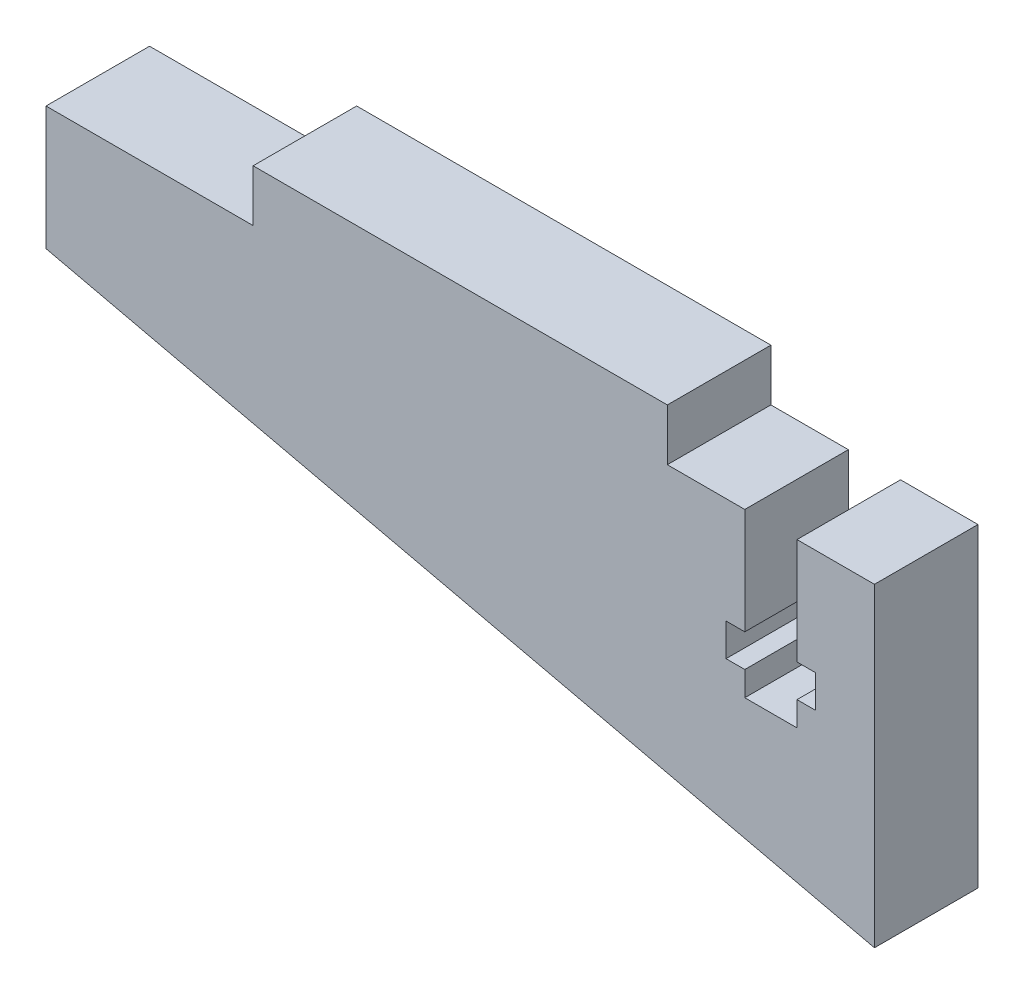
from build123d import *

# Parameters (mm, degrees)
BOSS_EXTRUDE1_DEPTH = 6.35


with BuildPart() as part:
    # Sketch1 → Boss-Extrude1 (new body)
    with BuildSketch(Plane.XY):
        Polygon((53.036987921, -0.166605104), (2.236987921, 11.561499005), (2.236987921, 19.137394896), (14.936987921, 19.137394896), (14.936987921, 22.312394896), (40.336987921, 22.312394896), (40.336987921, 19.137394896), (45.086987921, 19.137394896), (45.086987921, 12.637394896), (43.936987921, 12.637394896), (43.936987921, 10.637394896), (45.086987921, 10.637394896), (45.086987921, 9.137394896), (48.286987921, 9.137394896), (48.286987921, 10.637394896), (49.436987921, 10.637394896), (49.436987921, 12.637394896), (48.286987921, 12.637394896), (48.286987921, 19.137394896), (53.036987921, 19.137394896), align=None)
    extrude(amount=BOSS_EXTRUDE1_DEPTH)


solid = part.part
